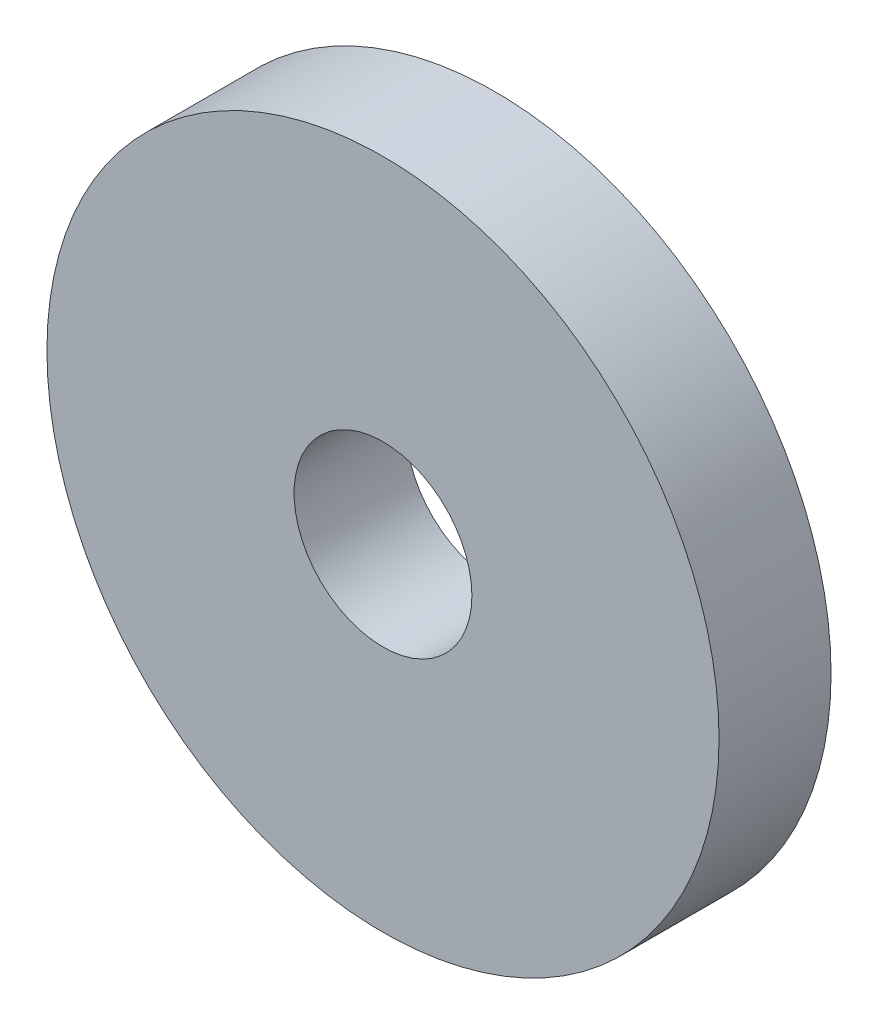
from build123d import *

# Parameters (mm, degrees)
SKETCH1_R           = 12
SKETCH1_R_2         = 3.175
BOSS_EXTRUDE1_DEPTH = 4


with BuildPart() as part:
    # Sketch1 → Boss-Extrude1 (new body)
    with BuildSketch(Plane.XY):
        Circle(SKETCH1_R)
        Circle(SKETCH1_R_2, mode=Mode.SUBTRACT)
    extrude(amount=BOSS_EXTRUDE1_DEPTH)


solid = part.part
